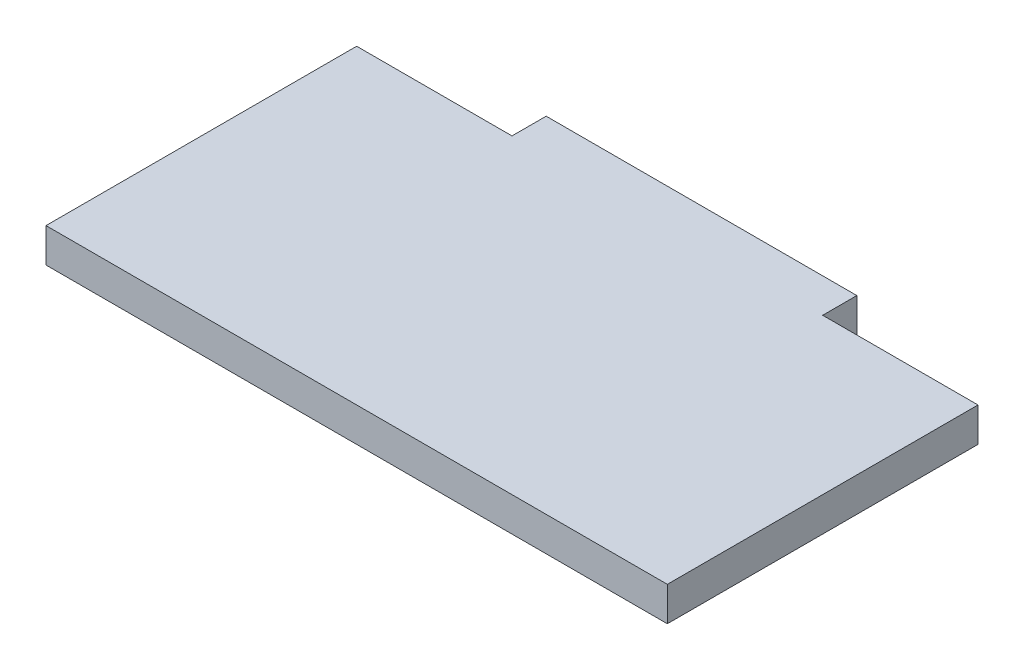
from build123d import *

# Parameters (mm, degrees)
BOSS_EXTRUDE1_DEPTH = 2.794


with BuildPart() as part:
    # Sketch1 → Boss-Extrude1 (new body)
    with BuildSketch(Plane(origin=(0, 0, 0), x_dir=(1, 0, 0), z_dir=(0, 1, 0))):
        Polygon((38.1, 25.4), (50.8, 25.4), (50.8, 0), (0, 0), (0, 25.4), (12.7, 25.4), (12.7, 28.194), (38.1, 28.194), align=None)
    extrude(amount=BOSS_EXTRUDE1_DEPTH)


solid = part.part
